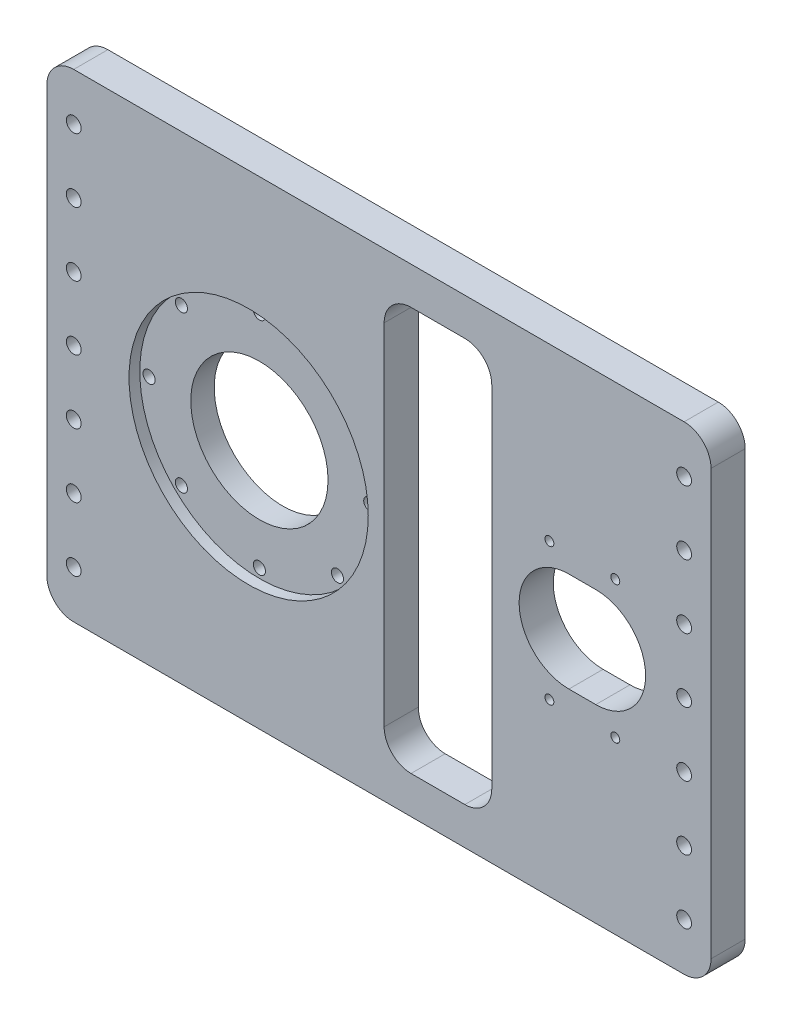
from build123d import *

# Parameters (mm, degrees)
SKETCH1_W                                           = 420
SKETCH1_H                                           = 190
BOSS_EXTRUDE1_DEPTH                                 = 12.7
FILLET1_R                                           = 10
SKETCH8_R                                           = 44.45
CUT_EXTRUDE1_DEPTH                                  = 4
SKETCH8_3_R                                         = 25.5
CUT_EXTRUDE2_DEPTH                                  = 13.7
CBORE_FOR_8_BINDING_HEAD_MACHINE_SCREW1_D           = 4.499991
CBORE_FOR_8_BINDING_HEAD_MACHINE_SCREW1_DEPTH       = 10
CBORE_FOR_8_BINDING_HEAD_MACHINE_SCREW1_CBORE_D     = 8.2499962
CBORE_FOR_8_BINDING_HEAD_MACHINE_SCREW1_CBORE_DEPTH = 3.999992
CBORE_FOR_8_BINDING_HEAD_MACHINE_SCREW1_TIP         = 1.351933689
CUT_EXTRUDE3_DEPTH                                  = 13.7
TAP_DRILL_FOR_M4X0_7_TAP1_D                         = 3.3
SKETCH18_W                                          = 135
SKETCH18_H                                          = 190
CUT_EXTRUDE4_DEPTH                                  = 13.7
FILLET2_R                                           = 10
SKETCH25_W                                          = 38.190452802
SKETCH25_H                                          = 150
CUT_EXTRUDE5_DEPTH                                  = 13.7
SKETCH26_W                                          = 40
SKETCH26_H                                          = 150
CUT_EXTRUDE6_DEPTH                                  = 13.7
FILLET4_R                                           = 10
CUT_EXTRUDE8_DEPTH                                  = 1
CUT_EXTRUDE8_DEPTH_BACK                             = 13.7
FILLET6_R                                           = 10
M5_CLEARANCE_HOLE4_D                                = 5.5
BOSS_EXTRUDE4_DEPTH                                 = 12.7
SKETCH42_W                                          = 246.809547198
SKETCH42_H                                          = 6.096
CUT_EXTRUDE9_DEPTH                                  = 12.7
FILLET7_R                                           = 10


with BuildPart() as part:
    # Sketch1 → Boss-Extrude1 (new body)
    with BuildSketch(Plane.XY):
        Rectangle(SKETCH1_W, SKETCH1_H)
    extrude(amount=BOSS_EXTRUDE1_DEPTH)

    # Fillet1
    fillet1_edges = [part.edges().sort_by_distance(p)[0] for p in [
        (210, -95, 6.35),
        (-210, -95, 6.35),
        (-210, 95, 6.35),
        (210, 95, 6.35),
    ]]
    fillet(fillet1_edges, radius=FILLET1_R)

    # Sketch8 → Cut-Extrude1 (cut)
    with BuildSketch(Plane.XY.offset(12.7)):
        Circle(SKETCH8_R)
    extrude(amount=-CUT_EXTRUDE1_DEPTH, mode=Mode.SUBTRACT)

    # Sketch8_3 → Cut-Extrude2 (cut, through all)
    with BuildSketch(Plane.XY.offset(12.7)):
        Circle(SKETCH8_3_R)
    extrude(amount=-CUT_EXTRUDE2_DEPTH, mode=Mode.SUBTRACT)

    # CBORE for _8 Binding Head Machine Screw1
    with Locations(Plane(origin=(0, 0, 0), x_dir=(-1, 0, 0), z_dir=(0, 0, -1))):
        with Locations((0, 41), (0, -41), (28.991378029, -28.991378029), (-28.991378029, -28.991378029), (-41, 0), (41, 0), (-28.991378029, 28.991378029), (28.991378029, 28.991378029)):
            CounterBoreHole(CBORE_FOR_8_BINDING_HEAD_MACHINE_SCREW1_D / 2, CBORE_FOR_8_BINDING_HEAD_MACHINE_SCREW1_CBORE_D / 2, CBORE_FOR_8_BINDING_HEAD_MACHINE_SCREW1_CBORE_DEPTH, depth=CBORE_FOR_8_BINDING_HEAD_MACHINE_SCREW1_DEPTH)
            with Locations((0, 0, -(CBORE_FOR_8_BINDING_HEAD_MACHINE_SCREW1_DEPTH + CBORE_FOR_8_BINDING_HEAD_MACHINE_SCREW1_TIP / 2))):  # 118° drill point
                Cone(0, CBORE_FOR_8_BINDING_HEAD_MACHINE_SCREW1_D / 2, CBORE_FOR_8_BINDING_HEAD_MACHINE_SCREW1_TIP, mode=Mode.SUBTRACT)

    # Sketch12 → Cut-Extrude3 (cut, through all)
    with BuildSketch(Plane.XY.offset(12.7)):
        with BuildLine():
            Line((119, -18.5), (129, -18.5))
            ThreePointArc((129, -18.5), (147.5, 0), (129, 18.5))
            Line((129, 18.5), (119, 18.5))
            ThreePointArc((119, 18.5), (100.5, 0), (119, -18.5))
        make_face()
    extrude(amount=-CUT_EXTRUDE3_DEPTH, mode=Mode.SUBTRACT)

    # Tap Drill for M4x0.7 Tap1 (through all)
    with Locations(Plane.XY.offset(12.7)):
        with Locations((111.75, 25.5), (136.25, 25.5), (111.75, -25.5), (136.25, -25.5)):
            Hole(TAP_DRILL_FOR_M4X0_7_TAP1_D / 2)

    # Sketch18 → Cut-Extrude4 (cut, through all)
    with BuildSketch(Plane.XY.offset(12.7)):
        with Locations((-142.5, 0)):
            Rectangle(SKETCH18_W, SKETCH18_H)
    extrude(amount=-CUT_EXTRUDE4_DEPTH, mode=Mode.SUBTRACT)

    # Fillet2
    fillet2_edges = [part.edges().sort_by_distance(p)[0] for p in [
        (-75, 95, 6.35),
        (-75, -95, 6.35),
    ]]
    fillet(fillet2_edges, radius=FILLET2_R)

    # Sketch25 → Cut-Extrude5 (cut, through all)
    with BuildSketch(Plane.XY.offset(12.7)):
        with Locations((190.904773599, 0)):
            Rectangle(SKETCH25_W, SKETCH25_H)
    extrude(amount=-CUT_EXTRUDE5_DEPTH, mode=Mode.SUBTRACT)

    # Sketch26 → Cut-Extrude6 (cut, through all)
    with BuildSketch(Plane.XY.offset(12.7)):
        with Locations((70.340308105, 0)):
            Rectangle(SKETCH26_W, SKETCH26_H)
    extrude(amount=-CUT_EXTRUDE6_DEPTH, mode=Mode.SUBTRACT)

    # Fillet4
    fillet4_edges = [part.edges().sort_by_distance(p)[0] for p in [
        (90.340308105, 75, 6.35),
        (90.340308105, -75, 6.35),
        (50.340308105, -75, 6.35),
        (50.340308105, 75, 6.35),
    ]]
    fillet(fillet4_edges, radius=FILLET4_R)

    # Sketch35 → Cut-Extrude8 (cut, two sides)
    with BuildSketch(Plane.XY.offset(12.7)) as cut_extrude8_sk:
        Polygon((171.809547198, -75), (171.809547198, -95), (219.38654528, -95), (219.38654528, 95), (171.809547198, 95), align=None)
    extrude(amount=CUT_EXTRUDE8_DEPTH, mode=Mode.SUBTRACT)
    extrude(cut_extrude8_sk.sketch, amount=-CUT_EXTRUDE8_DEPTH_BACK, mode=Mode.SUBTRACT)

    # Fillet6
    fillet6_edges = [part.edges().sort_by_distance(p)[0] for p in [
        (171.809547198, -95, 6.35),
        (171.809547198, 95, 6.35),
    ]]
    fillet(fillet6_edges, radius=FILLET6_R)

    # M5 Clearance Hole4 (through all)
    with Locations(Plane.XY.offset(12.7)):
        with Locations((161.809547198, -71.25), (161.809547198, -47.5), (161.809547198, -23.75), (161.809547198, 0), (161.809547198, 23.75), (161.809547198, 47.5), (161.809547198, 71.25), (-65, 71.25), (-65, 47.5), (-65, 23.75), (-65, 0), (-65, -23.75), (-65, -47.5), (-65, -71.25)):
            Hole(M5_CLEARANCE_HOLE4_D / 2)

    # Sketch41 → Boss-Extrude4 (add)
    with BuildSketch(Plane(origin=(0, 0, 0), x_dir=(-1, 0, 0), z_dir=(0, 0, -1))):
        with BuildLine():
            Line((75, 85), (75, 95))
            Line((75, 95), (65, 95))
            ThreePointArc((65, 95), (72.071067812, 92.071067812), (75, 85))
        make_face()
        with BuildLine():
            Line((75, -95), (65, -95))
            ThreePointArc((65, -95), (72.071067812, -92.071067812), (75, -85))
            Line((75, -85), (75, -95))
        make_face()
        with BuildLine():
            Line((-171.809547198, -85), (-171.809547198, -95))
            Line((-171.809547198, -95), (-161.809547198, -95))
            ThreePointArc((-161.809547198, -95), (-168.88061501, -92.071067812), (-171.809547198, -85))
        make_face()
        with BuildLine():
            Line((-171.809547198, 95), (-161.809547198, 95))
            ThreePointArc((-161.809547198, 95), (-168.88061501, 92.071067812), (-171.809547198, 85))
            Line((-171.809547198, 85), (-171.809547198, 95))
        make_face()
    extrude(amount=-BOSS_EXTRUDE4_DEPTH)

    # Sketch42 → Cut-Extrude9 (cut)
    with BuildSketch(Plane(origin=(0, 0, 0), x_dir=(-1, 0, 0), z_dir=(0, 0, -1))):
        with Locations((-48.404773599, 91.952)):
            Rectangle(SKETCH42_W, SKETCH42_H)
        with Locations((-48.404773599, -91.952)):
            Rectangle(SKETCH42_W, SKETCH42_H)
    extrude(amount=-CUT_EXTRUDE9_DEPTH, mode=Mode.SUBTRACT)

    # Fillet7
    fillet7_edges = [part.edges().sort_by_distance(p)[0] for p in [
        (171.809547198, 88.904, 6.35),
        (-75, 88.904, 6.35),
        (-75, -88.904, 6.35),
        (171.809547198, -88.904, 6.35),
    ]]
    fillet(fillet7_edges, radius=FILLET7_R)


solid = part.part
